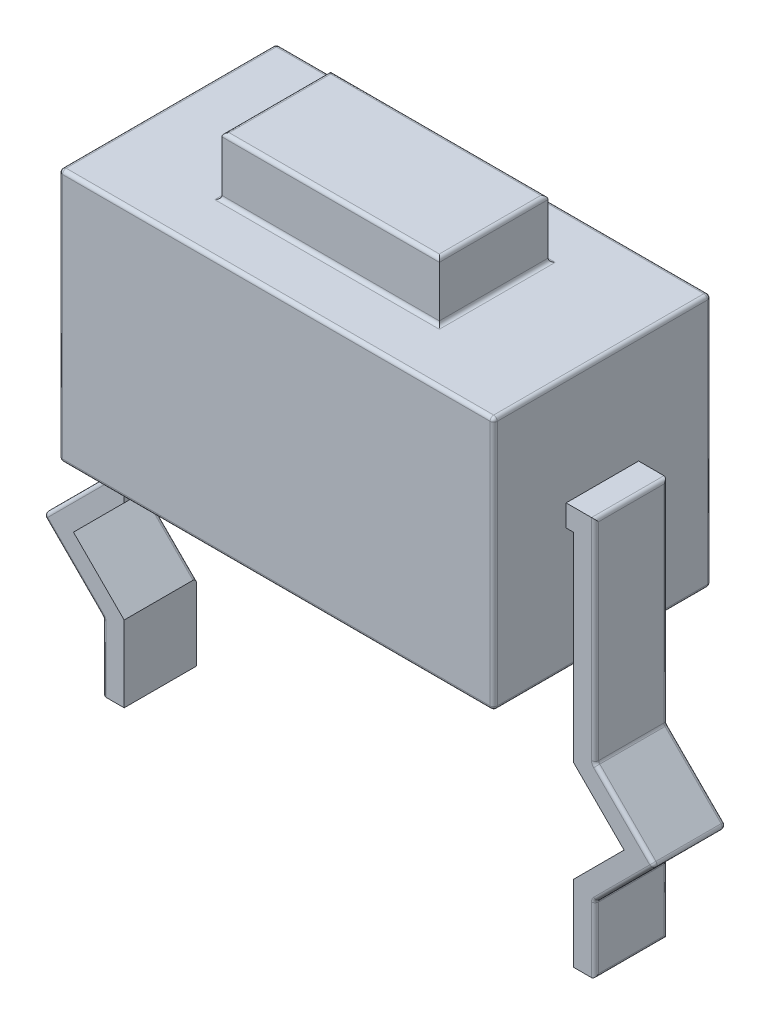
from build123d import *

# Parameters (mm, degrees)
SKETCH1_W           = 6
SKETCH1_H           = 3
BOSS_EXTRUDE1_DEPTH = 3.5
BOSS_EXTRUDE2_DEPTH = 0.5
SKETCH3_W           = 3
SKETCH3_H           = 1.5
BOSS_EXTRUDE3_DEPTH = 0.8
FILLET1_R           = 0.05


with BuildPart() as part:
    # Sketch1 → Boss-Extrude1 (new body)
    with BuildSketch(Plane(origin=(0, 0, 0), x_dir=(1, 0, 0), z_dir=(0, 1, 0))):
        with Locations((3, 1.5)):
            Rectangle(SKETCH1_W, SKETCH1_H)
    extrude(amount=BOSS_EXTRUDE1_DEPTH)

    # Sketch2 → Boss-Extrude2 (add, symmetric)
    with BuildSketch(Plane.XY.offset(-1.5)):
        Polygon((-0.1, 1.7), (0, 1.7), (0, 2), (-0.4, 2), (-0.4, -0.925735931), (-1.224264069, -1.75), (-0.4, -2.574264069), (-0.4, -3.5), (-0.1, -3.5), (-0.1, -2.45), (-0.8, -1.75), (-0.1, -1.05), (-0.1, -0.722730952), align=None)
    boss_extrude2 = extrude(amount=BOSS_EXTRUDE2_DEPTH, both=True)

    # Mirror1: Boss-Extrude2 across plane
    add(boss_extrude2.mirror(Plane.ZY.offset(-3)))

    # Sketch3 → Boss-Extrude3 (add)
    with BuildSketch(Plane(origin=(0, 3.5, 0), x_dir=(1, 0, 0), z_dir=(0, 1, 0))):
        with Locations((3, 1.5)):
            Rectangle(SKETCH3_W, SKETCH3_H)
    extrude(amount=BOSS_EXTRUDE3_DEPTH)

    # Fillet1
    fillet1_edges = [part.edges().sort_by_distance(p)[0] for p in [
        (6, 3.5, -1.5),
        (3, 3.5, -3),
        (-0.4, -3.5, -1.5),
        (-0.4, -3.037132034, -2),
        (-0.4, -2.574264069, -1.5),
        (-0.812132034, -2.162132034, -2),
        (-1.224264069, -1.75, -1.5),
        (-0.812132034, -1.337867966, -2),
        (-0.4, -0.925735931, -1.5),
        (-0.4, 0.537132034, -2),
        (-0.4, 2, -1.5),
        (0, 2, -1.5),
        (0, 1.85, -1),
        (0, 1.7, -1.5),
        (0, 1.85, -2),
        (-0.45, -2.1, -2),
        (-0.4, -3.037132034, -1),
        (-0.4, 0.537132034, -1),
        (-0.812132034, -1.337867966, -1),
        (-0.812132034, -2.162132034, -1),
        (0, 3.5, -1.5),
        (3, 0, -3),
        (6.4, -2.574264069, -1.5),
        (6.4, -3.037132034, -1),
        (6.4, -3.5, -1.5),
        (6.4, 2, -1.5),
        (6.4, 0.537132034, -1),
        (6, 0, -1.5),
        (6.4, -0.925735931, -1.5),
        (6.812132034, -1.337867966, -1),
        (7.224264069, -1.75, -1.5),
        (6.812132034, -2.162132034, -1),
        (6.4, -3.037132034, -2),
        (6.4, 0.537132034, -2),
        (6.812132034, -1.337867966, -2),
        (6.812132034, -2.162132034, -2),
        (3, 0, 0),
        (0, 0, -1.5),
        (3, 3.5, 0),
        (0, 1.75, -3),
        (4.5, 3.5, -1.5),
        (3, 3.5, -2.25),
        (6, 1.75, -3),
        (1.5, 3.5, -1.5),
        (3, 3.5, -0.75),
        (6, 1.75, 0),
        (4.5, 4.3, -1.5),
        (3, 4.3, -2.25),
        (1.5, 4.3, -1.5),
        (3, 4.3, -0.75),
        (0, 1.75, 0),
    ]]
    fillet(fillet1_edges, radius=FILLET1_R)


solid = part.part
